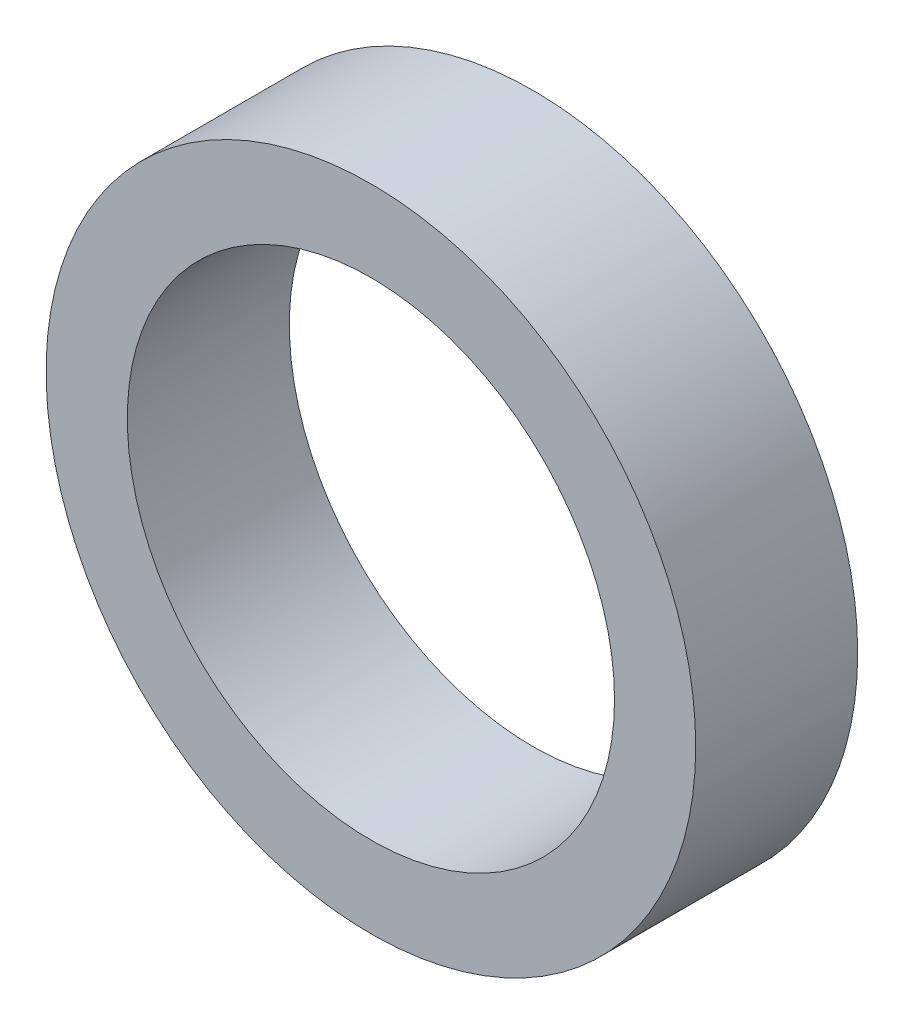
from build123d import *

# Parameters (mm, degrees)
SKETCH1_R           = 6.35
SKETCH1_R_2         = 4.7625
BOSS_EXTRUDE1_DEPTH = 3.16652148


with BuildPart() as part:
    # Sketch1 → Boss-Extrude1 (new body)
    with BuildSketch(Plane.XY):
        Circle(SKETCH1_R)
        Circle(SKETCH1_R_2, mode=Mode.SUBTRACT)
    extrude(amount=BOSS_EXTRUDE1_DEPTH)


solid = part.part
